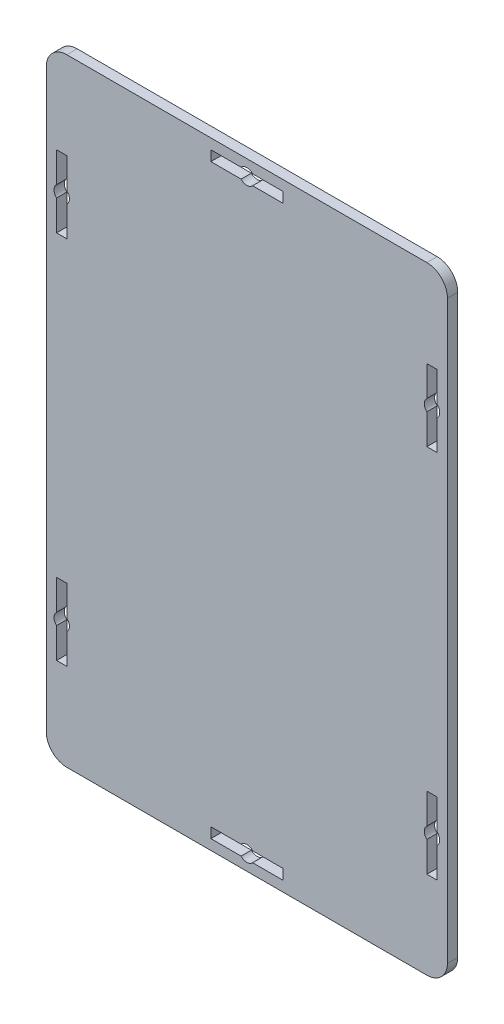
from build123d import *

# Parameters (mm, degrees)
SKETCH1_W                  = 78
SKETCH1_H                  = 120
MAIN_SLIDER_BOTTOM_DEPTH   = 2
SLIDER_BOTTOM_CONTOURING_R = 4


with BuildPart() as part:
    # Sketch1 → Main Slider Bottom (new body)
    with BuildSketch(Plane.XY):
        with Locations((39, 60)):
            Rectangle(SKETCH1_W, SKETCH1_H)
        with BuildLine():
            Line((40.118033989, 4), (46, 4))
            Line((46, 4), (46, 2))
            Line((46, 2), (40.118033989, 2))
            ThreePointArc((40.118033989, 2), (39, 1.5), (37.881966011, 2))
            Line((37.881966011, 2), (32, 2))
            Line((32, 2), (32, 4))
            Line((32, 4), (37.881966011, 4))
            ThreePointArc((37.881966011, 4), (39, 4.5), (40.118033989, 4))
        make_face(mode=Mode.SUBTRACT)
        with BuildLine():
            Line((40.118033989, 118), (46, 118))
            Line((46, 118), (46, 116))
            Line((46, 116), (40.118033989, 116))
            ThreePointArc((40.118033989, 116), (39, 115.5), (37.881966011, 116))
            Line((37.881966011, 116), (32, 116))
            Line((32, 116), (32, 118))
            Line((32, 118), (37.881966011, 118))
            ThreePointArc((37.881966011, 118), (39, 118.5), (40.118033989, 118))
        make_face(mode=Mode.SUBTRACT)
        with BuildLine():
            Line((74, 97.118033989), (74, 103))
            Line((74, 103), (76, 103))
            Line((76, 103), (76, 97.118033989))
            ThreePointArc((76, 97.118033989), (76.5, 96), (76, 94.881966011))
            Line((76, 94.881966011), (76, 89))
            Line((76, 89), (74, 89))
            Line((74, 89), (74, 94.881966011))
            ThreePointArc((74, 94.881966011), (73.5, 96), (74, 97.118033989))
        make_face(mode=Mode.SUBTRACT)
        with BuildLine():
            Line((4, 97.118033989), (4, 103))
            Line((4, 103), (2, 103))
            Line((2, 103), (2, 97.118033989))
            ThreePointArc((2, 97.118033989), (1.5, 96), (2, 94.881966011))
            Line((2, 94.881966011), (2, 89))
            Line((2, 89), (4, 89))
            Line((4, 89), (4, 94.881966011))
            ThreePointArc((4, 94.881966011), (4.5, 96), (4, 97.118033989))
        make_face(mode=Mode.SUBTRACT)
        with BuildLine():
            Line((2, 22.881966011), (2, 17))
            Line((2, 17), (4, 17))
            Line((4, 17), (4, 22.881966011))
            ThreePointArc((4, 22.881966011), (4.5, 24), (4, 25.118033989))
            Line((4, 25.118033989), (4, 31))
            Line((4, 31), (2, 31))
            Line((2, 31), (2, 25.118033989))
            ThreePointArc((2, 25.118033989), (1.5, 24), (2, 22.881966011))
        make_face(mode=Mode.SUBTRACT)
        with BuildLine():
            Line((74, 22.881966011), (74, 17))
            Line((74, 17), (76, 17))
            Line((76, 17), (76, 22.881966011))
            ThreePointArc((76, 22.881966011), (76.5, 24), (76, 25.118033989))
            Line((76, 25.118033989), (76, 31))
            Line((76, 31), (74, 31))
            Line((74, 31), (74, 25.118033989))
            ThreePointArc((74, 25.118033989), (73.5, 24), (74, 22.881966011))
        make_face(mode=Mode.SUBTRACT)
    extrude(amount=MAIN_SLIDER_BOTTOM_DEPTH)

    # Slider Bottom Contouring
    slider_bottom_contouring_edges = [part.edges().sort_by_distance(p)[0] for p in [
        (0, 120, 1),
        (78, 120, 1),
        (78, 0, 1),
        (0, 0, 1),
    ]]
    fillet(slider_bottom_contouring_edges, radius=SLIDER_BOTTOM_CONTOURING_R)


solid = part.part
